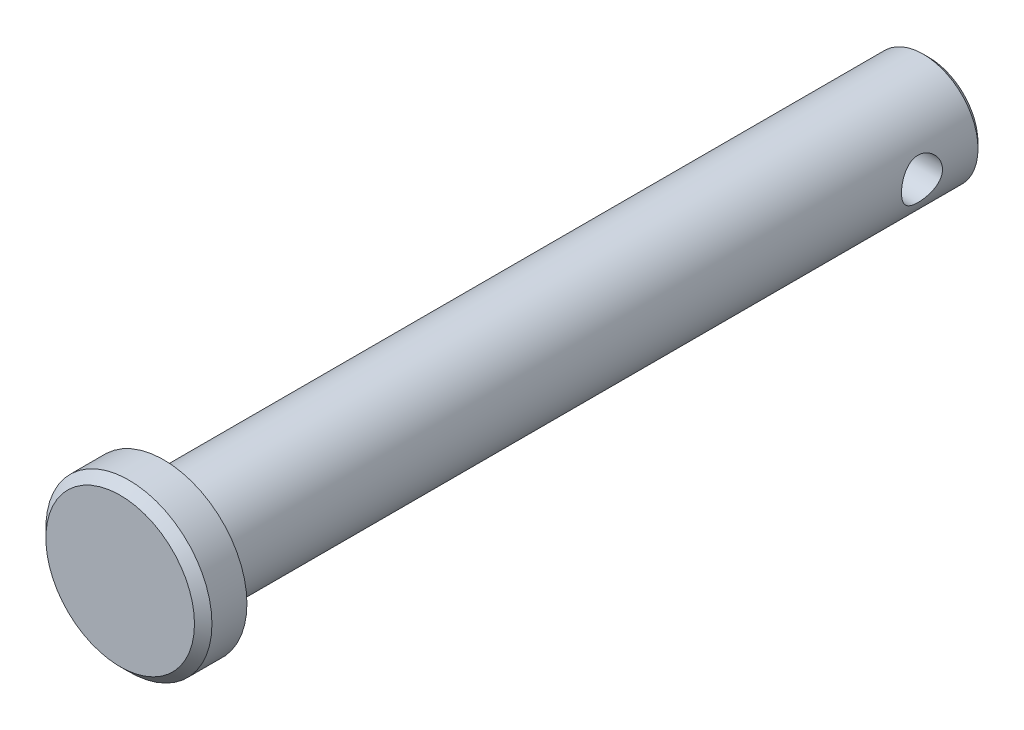
from build123d import *

# Parameters (mm, degrees)
SKETCH1_R           = 3.175
EXTRUDE1_DEPTH      = 22.225
SKETCH2_R           = 4.826
EXTRUDE2_DEPTH      = 2.54
CHAMFER1_SIZE       = 0.508
SKETCH3_R           = 1.190625
EXTRUDE3_DEPTH      = 5.826
EXTRUDE3_DEPTH_BACK = 5.826
CHAMFER2_SIZE       = 0.3175


with BuildPart() as part:
    # Sketch1 → Extrude1 (new body, symmetric)
    with BuildSketch(Plane.XY):
        Circle(SKETCH1_R)
    extrude(amount=EXTRUDE1_DEPTH, both=True)

    # Sketch2 → Extrude2 (add)
    with BuildSketch(Plane.XY.offset(22.225)):
        Circle(SKETCH2_R)
    extrude(amount=EXTRUDE2_DEPTH)

    # Chamfer1
    chamfer1_edges = [part.edges().sort_by_distance(p)[0] for p in [
        (-4.826, 0, 24.765),
    ]]
    chamfer(chamfer1_edges, length=CHAMFER1_SIZE)

    # Sketch3 → Extrude3 (cut, two sides)
    with BuildSketch(Plane(origin=(0, 0, 0), x_dir=(0, 0, -1), z_dir=(1, 0, 0))) as extrude3_sk:
        with Locations((18.653125, 0)):
            Circle(SKETCH3_R)
    extrude(amount=EXTRUDE3_DEPTH, mode=Mode.SUBTRACT)
    extrude(extrude3_sk.sketch, amount=-EXTRUDE3_DEPTH_BACK, mode=Mode.SUBTRACT)

    # Chamfer2
    chamfer2_edges = [part.edges().sort_by_distance(p)[0] for p in [
        (-3.175, 0, -22.225),
    ]]
    chamfer(chamfer2_edges, length=CHAMFER2_SIZE)


solid = part.part
